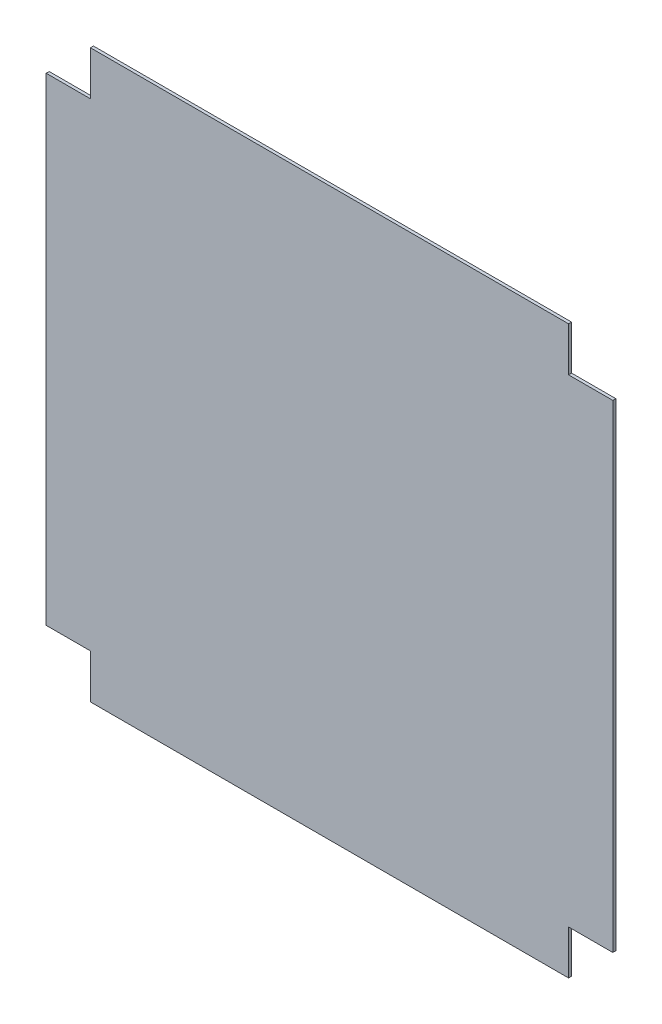
from build123d import *

# Parameters (mm, degrees)
EXTRUDE_1_DEPTH = 1.5


with BuildPart() as part:
    # 草圖1 → 填料-伸長1 (new body)
    with BuildSketch(Plane.XY):
        Polygon((-80.932998214, 58.795366795), (157.067001786, 58.795366795), (157.067001786, 36.795366795), (179.067001786, 36.795366795), (179.067001786, -201.204633205), (157.067001786, -201.204633205), (157.067001786, -223.204633205), (-80.932998214, -223.204633205), (-80.932998214, -201.204633205), (-102.932998214, -201.204633205), (-102.932998214, 36.795366795), (-80.932998214, 36.795366795), align=None)
    extrude(amount=EXTRUDE_1_DEPTH)


solid = part.part
